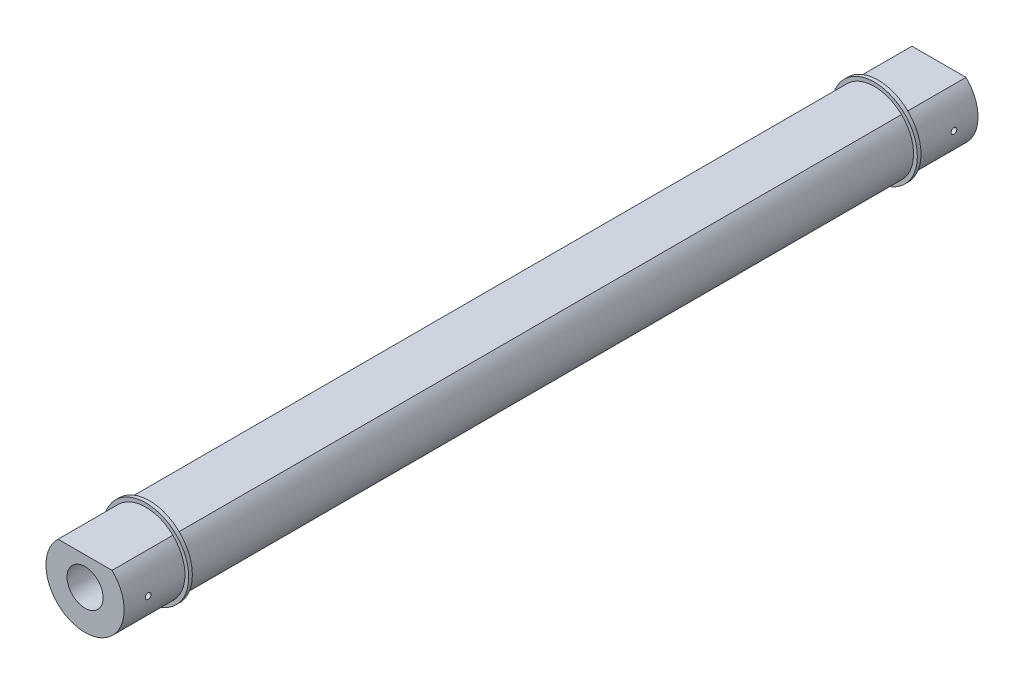
from build123d import *

# Parameters (mm, degrees)
RACK_DEPTH             = 112.7125
RACK_DEPTH_BACK        = 112.7125
SKETCH2_R              = 4.7625
END_HOLE_DEPTH         = 25.4
BUMP_START             = -17.018
SKETCH3_R              = 11.3157
SKETCH3_R_2            = 10.31875
BUMP_STOP_DEPTH        = 0.9652
SKETCH4_R              = 0.762
SAFETY_WIRE_HOLE_DEPTH = 12.3157


with BuildPart() as part:
    # Sketch1 → Rack (new body, two sides)
    with BuildSketch(Plane.XY) as rack_sk:
        with BuildLine():
            Line((7.127857322, 7.46125), (-7.127857322, 7.46125))
            ThreePointArc((-7.127857322, 7.46125), (-4.057463729, -9.487549191), (10.31875, 0))
            ThreePointArc((10.31875, 0), (9.487549191, 4.057463729), (7.127857322, 7.46125))
        make_face()
    extrude(amount=RACK_DEPTH)
    extrude(rack_sk.sketch, amount=-RACK_DEPTH_BACK)

    # Sketch2 → End Hole (cut)
    with BuildSketch(Plane.XY.offset(112.7125)):
        Circle(SKETCH2_R)
    end_hole = extrude(amount=-END_HOLE_DEPTH, mode=Mode.SUBTRACT)

    # Sketch3 → Bump Stop (add)
    with BuildSketch(Plane.XY.offset(112.7125).offset(BUMP_START)):
        Circle(SKETCH3_R)
        Circle(SKETCH3_R_2, mode=Mode.SUBTRACT)
    bump_stop = extrude(amount=BUMP_STOP_DEPTH)

    # Sketch4 → Safety Wire Hole (cut, symmetric)
    with BuildSketch(Plane(origin=(0, 0, 0), x_dir=(0, 0, -1), z_dir=(1, 0, 0))):
        with Locations((-106.3625, 0)):
            Circle(SKETCH4_R)
    safety_wire_hole = extrude(amount=SAFETY_WIRE_HOLE_DEPTH, both=True, mode=Mode.SUBTRACT)

    # Rack Mirror: End Hole, Bump Stop, Safety Wire Hole across plane
    add(end_hole.mirror(Plane.XY), mode=Mode.SUBTRACT)
    add(bump_stop.mirror(Plane.XY))
    add(safety_wire_hole.mirror(Plane.XY), mode=Mode.SUBTRACT)


solid = part.part
